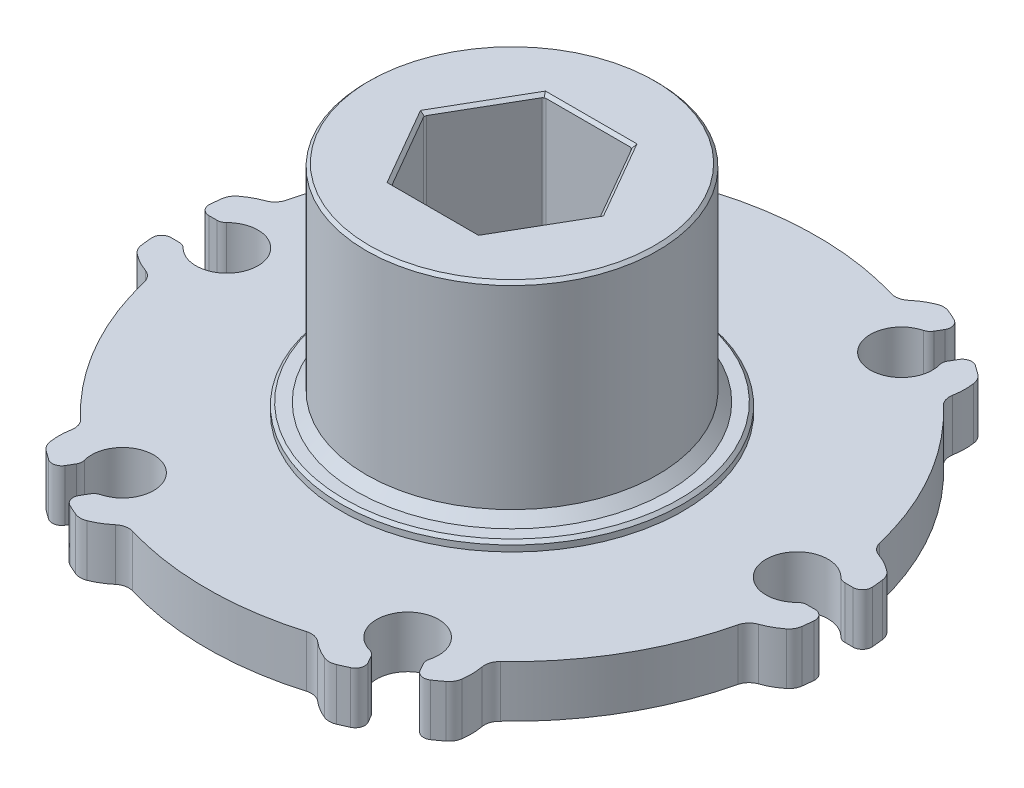
from build123d import *

# Parameters (mm, degrees)
SKETCH1_R                = 27.7876
BOSS_EXTRUDE1_DEPTH      = 8.128
CUT_EXTRUDE1_DEPTH       = 9.128
FILLET4_R                = 0.7874
CIRPATTERN1_COUNT        = 6
FILLET4_OF_CIRPATTERN1_R = 0.7874
SKETCH9_R                = 12.1666
BOSS_EXTRUDE2_DEPTH      = 17.272
SKETCH10_R               = 6.4643
CUT_EXTRUDE2_DEPTH       = 26.4
SKETCH11_W               = 16.1036
SKETCH11_H               = 3.3147
CUT_EXTRUDE3_DEPTH       = 26.4
CHAMFER1_SIZE            = 0.254
FILLET5_R                = 0.127
CHAMFER2_SIZE            = 0.8128
SKETCH12_W               = 23.8252
SKETCH12_H               = 5.08
CHAMFER3_SIZE            = 0.254
SKETCH13_R               = 9.23823544
BOSS_EXTRUDE3_DEPTH      = 25.4
CUT_EXTRUDE4_DEPTH       = 26.4
CHAMFER4_SIZE            = 0.254
CUT_EXTRUDE5_DEPTH       = 26.4
CIRPATTERN2_COUNT        = 6
FILLET6_R                = 1.27
CHAMFER5_SIZE            = 0.254
FILLET7_R                = 0.254


with BuildPart() as part:
    # Sketch1 → Boss-Extrude1 (new body)
    with BuildSketch(Plane(origin=(0, 0, 0), x_dir=(1, 0, 0), z_dir=(0, 1, 0))):
        Circle(SKETCH1_R)
    extrude(amount=BOSS_EXTRUDE1_DEPTH)

    # Sketch6 → Cut-Extrude1 (cut, through all)
    with BuildSketch(Plane(origin=(0, 8.128, 0), x_dir=(1, 0, 0), z_dir=(0, 1, 0))):
        with BuildLine():
            Line((25.859959008, 1.5875), (37.457436379, 1.5875))
            Line((37.457436379, 1.5875), (37.457436379, -1.5875))
            Line((37.457436379, -1.5875), (25.859959008, -1.5875))
            ThreePointArc((25.859959008, -1.5875), (21.2217, 0), (25.859959008, 1.5875))
        make_face()
    cut_extrude1 = extrude(amount=-CUT_EXTRUDE1_DEPTH, mode=Mode.SUBTRACT)

    # Fillet4
    fillet4_edges = [part.edges().sort_by_distance(p)[0] for p in [
        (25.859959008, 4.064, -1.5875),
        (27.742216161, 4.064, 1.5875),
        (27.742216161, 4.064, -1.5875),
        (25.859959008, 4.064, 1.5875),
    ]]
    fillet(fillet4_edges, radius=FILLET4_R)

    # CirPattern1: Cut-Extrude1 ×6 about axis
    cirpattern1_axis = Axis((0, 0, 0), (0, 1, 0))
    for i in range(1, CIRPATTERN1_COUNT):
        add(cut_extrude1.rotate(cirpattern1_axis, i * 360 / CIRPATTERN1_COUNT), mode=Mode.SUBTRACT)

    # Fillet4 of CirPattern1
    fillet4_of_cirpattern1_edges = [part.edges().sort_by_distance(p)[0] for p in [
        (11.555164176, 4.064, -23.189131442),
        (15.245923409, 4.064, -23.231713952),
        (12.496292752, 4.064, -24.819213952),
        (14.304794833, 4.064, -21.601631442),
        (-14.304794833, 4.064, -21.601631442),
        (-12.496292752, 4.064, -24.819213952),
        (-15.245923409, 4.064, -23.231713952),
        (-11.555164176, 4.064, -23.189131442),
        (-25.859959008, 4.064, 1.5875),
        (-27.742216161, 4.064, -1.5875),
        (-27.742216161, 4.064, 1.5875),
        (-25.859959008, 4.064, -1.5875),
        (-11.555164176, 4.064, 23.189131442),
        (-15.245923409, 4.064, 23.231713952),
        (-12.496292752, 4.064, 24.819213952),
        (-14.304794833, 4.064, 21.601631442),
        (14.304794833, 4.064, 21.601631442),
        (12.496292752, 4.064, 24.819213952),
        (15.245923409, 4.064, 23.231713952),
        (11.555164176, 4.064, 23.189131442),
    ]]
    fillet(fillet4_of_cirpattern1_edges, radius=FILLET4_OF_CIRPATTERN1_R)

    # Sketch9 → Boss-Extrude2 (add)
    with BuildSketch(Plane(origin=(0, 8.128, 0), x_dir=(-1, 0, 0), z_dir=(0, 1, 0))):
        Circle(SKETCH9_R)
    extrude(amount=BOSS_EXTRUDE2_DEPTH)

    # Sketch10 → Cut-Extrude2 (cut, through all)
    with BuildSketch(Plane(origin=(0, 25.4, 0), x_dir=(1, 0, 0), z_dir=(0, 1, 0))):
        Circle(SKETCH10_R)
    extrude(amount=-CUT_EXTRUDE2_DEPTH, mode=Mode.SUBTRACT)

    # Sketch11 → Cut-Extrude3 (cut, through all)
    with BuildSketch(Plane(origin=(0, 25.4, 0), x_dir=(1, 0, 0), z_dir=(0, 1, 0))):
        Rectangle(SKETCH11_W, SKETCH11_H)
    extrude(amount=-CUT_EXTRUDE3_DEPTH, mode=Mode.SUBTRACT)

    # Chamfer1
    chamfer1_edges = [part.edges().sort_by_distance(p)[0] for p in [
        (12.1666, 25.4, 0),
        (0, 0, -6.4643),
        (0, 0, 6.4643),
        (0, 25.4, -6.4643),
        (0, 25.4, 6.4643),
    ]]
    chamfer(chamfer1_edges, length=CHAMFER1_SIZE)

    # Fillet5
    fillet5_edges = [part.edges().sort_by_distance(p)[0] for p in [
        (6.248228986, 12.7, 1.65735),
        (-6.248228986, 12.7, 1.65735),
        (-8.0518, 12.7, 1.65735),
        (-8.0518, 12.7, -1.65735),
        (-6.248228986, 12.7, -1.65735),
        (6.248228986, 12.7, -1.65735),
        (8.0518, 12.7, -1.65735),
        (8.0518, 12.7, 1.65735),
    ]]
    fillet(fillet5_edges, radius=FILLET5_R)

    # Chamfer2
    chamfer2_edges = [part.edges().sort_by_distance(p)[0] for p in [
        (12.1666, 8.128, 0),
    ]]
    chamfer(chamfer2_edges, length=CHAMFER2_SIZE)

    # Sketch12 → Cut-Revolve1 (revolve, cut)
    with BuildSketch(Plane.XY):
        with Locations((-26.1874, 9.906)):
            Rectangle(SKETCH12_W, SKETCH12_H)
        Polygon((-38.1, 3.048), (-14.2748, 3.048), (-14.2748, 1.524), (-8.89, 1.524), (-8.89, -2.032), (-14.2875, -2.032), (-38.1, -2.032), align=None)
    revolve(axis=Axis((0, -1.075785146, 0), (0, 1, 0)), mode=Mode.SUBTRACT)

    # Chamfer3
    chamfer3_edges = [part.edges().sort_by_distance(p)[0] for p in [
        (14.2748, 8.128, 0),
        (14.2748, 1.524, 0),
    ]]
    chamfer(chamfer3_edges, length=CHAMFER3_SIZE)

    # Sketch13 → Boss-Extrude3 (add)
    with BuildSketch(Plane(origin=(0, 25.4, 0), x_dir=(1, 0, 0), z_dir=(0, 1, 0))):
        Circle(SKETCH13_R)
    extrude(amount=-BOSS_EXTRUDE3_DEPTH)

    # Sketch14 → Cut-Extrude4 (cut, through all)
    with BuildSketch(Plane(origin=(0, 25.4, 0), x_dir=(1, 0, 0), z_dir=(0, 1, 0))):
        Polygon((7.347013116, 0), (3.673506558, 6.3627), (-3.673506558, 6.3627), (-7.347013116, 0), (-3.673506558, -6.3627), (3.673506558, -6.3627), align=None)
    extrude(amount=-CUT_EXTRUDE4_DEPTH, mode=Mode.SUBTRACT)

    # Chamfer4
    chamfer4_edges = [part.edges().sort_by_distance(p)[0] for p in [
        (5.510259837, 0, 3.18135),
        (0, 0, 6.3627),
        (-5.510259837, 0, 3.18135),
        (-5.510259837, 0, -3.18135),
        (0, 0, -6.3627),
        (5.510259837, 0, -3.18135),
        (5.510259837, 25.4, 3.18135),
        (5.510259837, 25.4, -3.18135),
        (0, 25.4, -6.3627),
        (-5.510259837, 25.4, -3.18135),
        (-5.510259837, 25.4, 3.18135),
        (0, 25.4, 6.3627),
    ]]
    chamfer(chamfer4_edges, length=CHAMFER4_SIZE)

    # Sketch15 → Cut-Extrude5 (cut, through all)
    with BuildSketch(Plane.XZ):
        with BuildLine():
            ThreePointArc((-17.527955912, 18.505533895), (-22.074034915, 12.74445), (-24.79024042, 5.926888149))
            ThreePointArc((-24.79024042, 5.926888149), (-25.080657079, 5.373490839), (-25.599865957, 5.025622244))
            ThreePointArc((-25.599865957, 5.025622244), (-27.243026047, 4.08448859), (-28.453842, 2.628592863))
            ThreePointArc((-28.453842, 2.628592863), (-24.746675913, 14.2875), (-16.503349196, 23.327453576))
            ThreePointArc((-16.503349196, 23.327453576), (-17.158783904, 21.550908338), (-17.152249511, 19.65732313))
            ThreePointArc((-17.152249511, 19.65732313), (-17.193908113, 19.033740755), (-17.527955912, 18.505533895))
        make_face()
    cut_extrude5 = extrude(amount=-CUT_EXTRUDE5_DEPTH, mode=Mode.SUBTRACT)

    # CirPattern2: Cut-Extrude5 ×6 about axis
    cirpattern2_axis = Axis((0, 0, 0), (0, 1, 0))
    for i in range(1, CIRPATTERN2_COUNT):
        add(cut_extrude5.rotate(cirpattern2_axis, i * 360 / CIRPATTERN2_COUNT), mode=Mode.SUBTRACT)

    # Fillet6
    fillet6_edges = [part.edges().sort_by_distance(p)[0] for p in [
        (-27.521980347, 5.207, 3.832924674),
        (-17.080400312, 5.207, 21.918271806),
        (-17.080400312, 5.207, -21.918271806),
        (-27.521980347, 5.207, -3.832924674),
        (10.441580035, 5.207, -25.75119648),
        (-10.441580035, 5.207, -25.75119648),
        (27.521980347, 5.207, -3.832924674),
        (17.080400312, 5.207, -21.918271806),
        (17.080400312, 5.207, 21.918271806),
        (27.521980347, 5.207, 3.832924674),
        (-10.441580035, 5.207, 25.75119648),
        (10.441580035, 5.207, 25.75119648),
    ]]
    fillet(fillet6_edges, radius=FILLET6_R)

    # Chamfer5
    chamfer5_edges = [part.edges().sort_by_distance(p)[0] for p in [
        (-9.23823544, 0, 0),
    ]]
    chamfer(chamfer5_edges, length=CHAMFER5_SIZE)

    # Fillet7
    fillet7_edges = [part.edges().sort_by_distance(p)[0] for p in [
        (3.673506558, 12.7, 6.3627),
        (-3.673506558, 12.7, 6.3627),
        (-7.347013116, 12.7, 0),
        (-3.673506558, 12.7, -6.3627),
        (3.673506558, 12.7, -6.3627),
        (7.347013116, 12.7, 0),
    ]]
    fillet(fillet7_edges, radius=FILLET7_R)


solid = part.part
